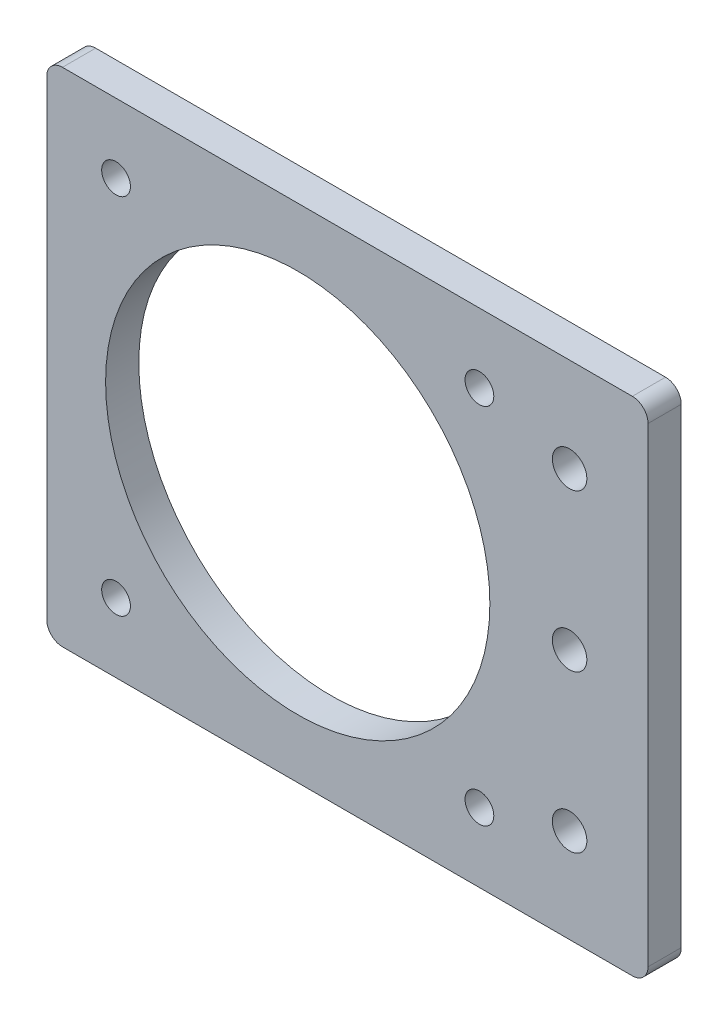
from build123d import *

# Parameters (mm, degrees)
SKETCH1_W                = 115
SKETCH1_H                = 96
BOSS_EXTRUDE1_DEPTH      = 6.35
SKETCH2_R                = 36.75
CUT_EXTRUDE1_DEPTH       = 7.35
FILLET1_R                = 3
M6_CLEARANCE_HOLE1_D     = 6.6
M6_CLEARANCE_HOLE1_DEPTH = 20
M6_CLEARANCE_HOLE1_TIP   = 1.982840043
M5_CLEARANCE_HOLE1_D     = 5.5


with BuildPart() as part:
    # Sketch1 → Boss-Extrude1 (new body)
    with BuildSketch(Plane.XY):
        Rectangle(SKETCH1_W, SKETCH1_H)
    extrude(amount=BOSS_EXTRUDE1_DEPTH)

    # Sketch2 → Cut-Extrude1 (cut, through all)
    with BuildSketch(Plane.XY.offset(6.35)):
        with Locations((-9.5, 0)):
            Circle(SKETCH2_R)
    extrude(amount=-CUT_EXTRUDE1_DEPTH, mode=Mode.SUBTRACT)

    # Fillet1
    fillet1_edges = [part.edges().sort_by_distance(p)[0] for p in [
        (57.5, -48, 3.175),
        (-57.5, -48, 3.175),
        (-57.5, 48, 3.175),
        (57.5, 48, 3.175),
    ]]
    fillet(fillet1_edges, radius=FILLET1_R)

    # M6 Clearance Hole1
    with Locations(Plane.XY.offset(6.35)):
        with Locations((42.5, 30), (42.5, 0), (42.5, -30)):
            Hole(M6_CLEARANCE_HOLE1_D / 2, depth=M6_CLEARANCE_HOLE1_DEPTH)
            with Locations((0, 0, -(M6_CLEARANCE_HOLE1_DEPTH + M6_CLEARANCE_HOLE1_TIP / 2))):  # 118° drill point
                Cone(0, M6_CLEARANCE_HOLE1_D / 2, M6_CLEARANCE_HOLE1_TIP, mode=Mode.SUBTRACT)

    # M5 Clearance Hole1 (through all)
    with Locations(Plane.XY.offset(6.35)):
        with Locations((25.25, -34.75), (-44.25, -34.75), (-44.25, 34.75), (25.25, 34.75)):
            Hole(M5_CLEARANCE_HOLE1_D / 2)


solid = part.part
